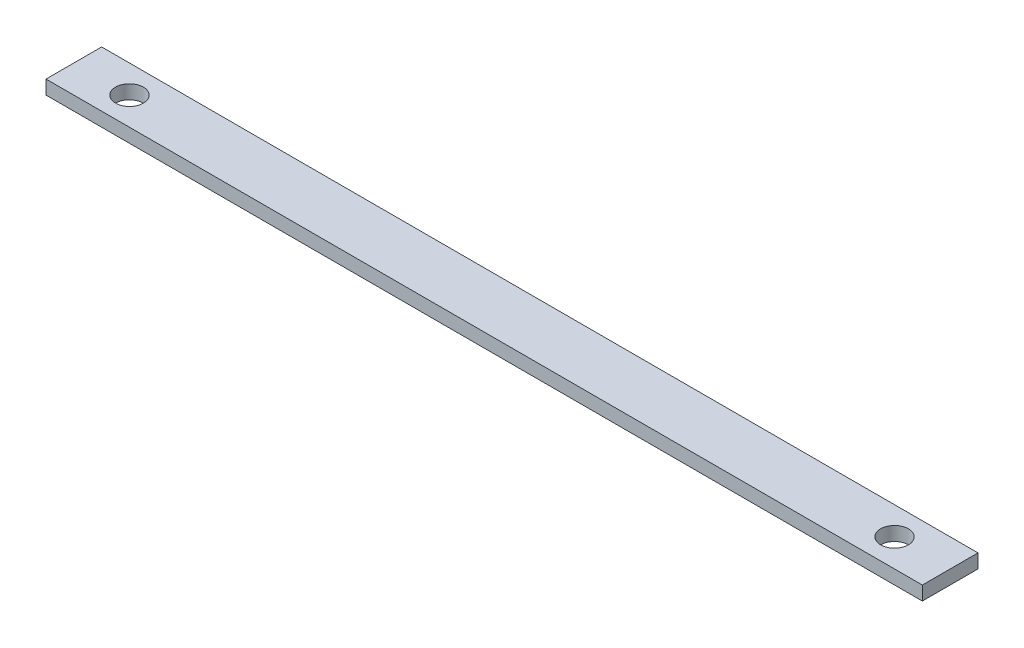
from build123d import *

# Parameters (mm, degrees)
SKETCH1_W           = 200
SKETCH1_H           = 12.7
BOSS_EXTRUDE1_DEPTH = 3.175
SKETCH2_R           = 3.175
CUT_EXTRUDE1_DEPTH  = 4.175


with BuildPart() as part:
    # Sketch1 → Boss-Extrude1 (new body)
    with BuildSketch(Plane(origin=(0, 0, 0), x_dir=(1, 0, 0), z_dir=(0, 1, 0))):
        with Locations((100, 6.35)):
            Rectangle(SKETCH1_W, SKETCH1_H)
    extrude(amount=BOSS_EXTRUDE1_DEPTH)

    # Sketch2 → Cut-Extrude1 (cut, through all)
    with BuildSketch(Plane(origin=(0, 3.175, 0), x_dir=(1, 0, 0), z_dir=(0, 1, 0))):
        with Locations((12.7, 6.35)):
            Circle(SKETCH2_R)
        with Locations((187.3, 6.35)):
            Circle(SKETCH2_R)
    extrude(amount=-CUT_EXTRUDE1_DEPTH, mode=Mode.SUBTRACT)


solid = part.part
